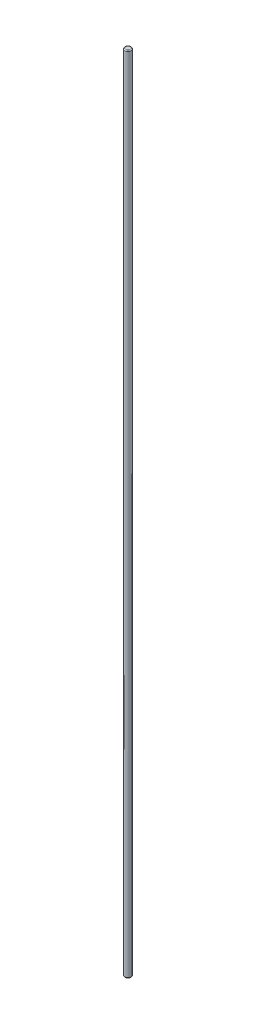
from build123d import *

# Parameters (mm, degrees)
SKETCH1_R           = 11.25
BOSS_EXTRUDE1_DEPTH = 2850
FILLET1_R           = 3


with BuildPart() as part:
    # Sketch1 → Boss-Extrude1 (new body)
    with BuildSketch(Plane(origin=(0, 0, 0), x_dir=(1, 0, 0), z_dir=(0, 1, 0))):
        Circle(SKETCH1_R)
    extrude(amount=BOSS_EXTRUDE1_DEPTH)

    # Fillet1
    fillet1_edges = [part.edges().sort_by_distance(p)[0] for p in [
        (-11.25, 0, 0),
        (-11.25, 2850, 0),
    ]]
    fillet(fillet1_edges, radius=FILLET1_R)


solid = part.part
